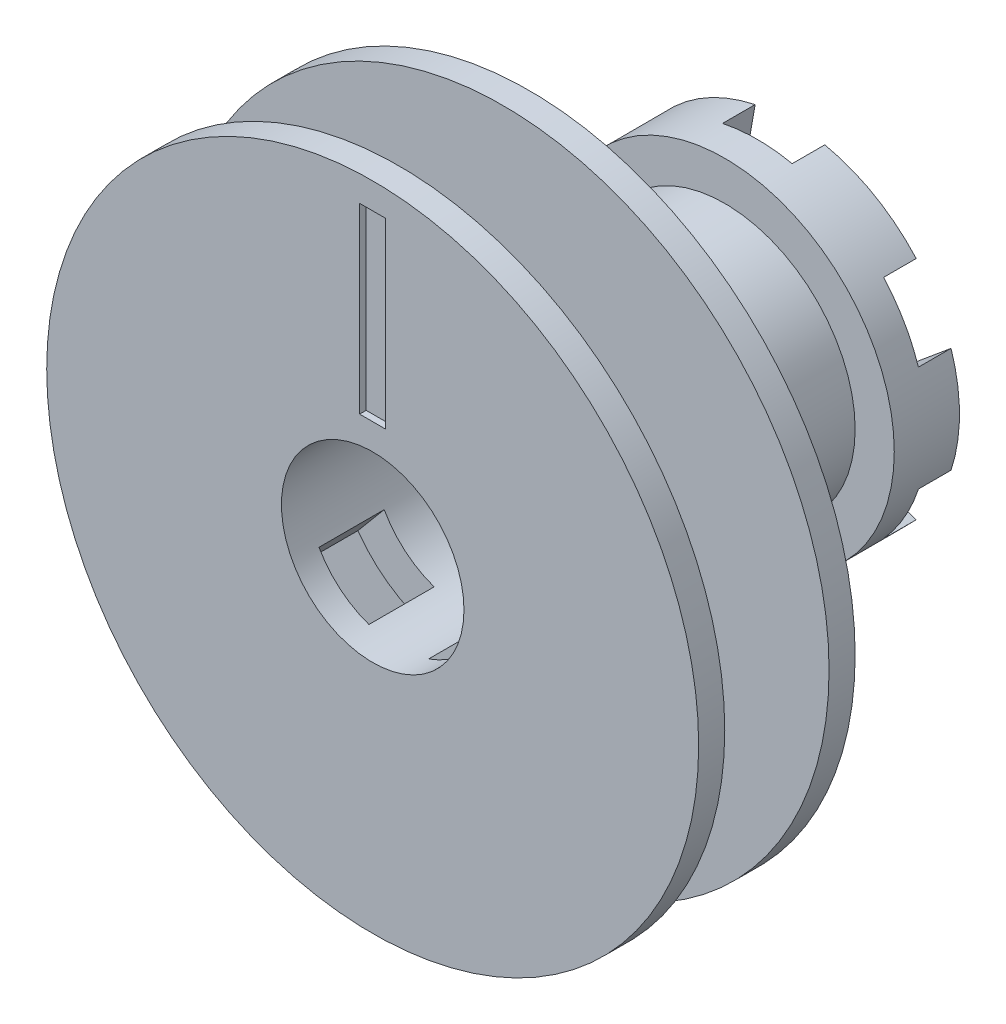
from build123d import *

# Parameters (mm, degrees)
SKETCH_3_R          = 13
EXTRUDE_1_DEPTH     = 5
CUT_EXTRUDE_2_DEPTH = 2.5
SKETCH_11_R         = 10
EXTRUDE_2_DEPTH     = 15
SKETCH_6_R          = 2
CUT_EXTRUDE_3_DEPTH = 33
SKETCH_7_R          = 7
CUT_EXTRUDE_4_DEPTH = 23
CUT_EXTRUDE_6_DEPTH = 5
FILLET_1_R          = 1
SKETCH_10_W         = 2
SKETCH_10_H         = 14
CUT_EXTRUDE_7_DEPTH = 0.5


with BuildPart() as part:
    # ｽｹｯﾁ3 → ﾎﾞｽ - 押し出し1 (new body)
    with BuildSketch(Plane.XY):
        Circle(SKETCH_3_R)
    extrude(amount=EXTRUDE_1_DEPTH)

    # ｽｹｯﾁ2 → ｶｯﾄ - 押し出し2 (cut)
    with BuildSketch(Plane.XY):
        with BuildLine():
            Line((3.75, 6.495190528), (2.463350586, 13.926501921))
            ThreePointArc((2.463350586, 13.926501921), (0, 16), (-2.463350586, 13.926501921))
            Line((-2.463350586, 13.926501921), (-3.75, 6.495190528))
            Line((-3.75, 6.495190528), (-10.829029157, 9.096575147))
            ThreePointArc((-10.829029157, 9.096575147), (-13.856406461, 8), (-13.292379743, 4.829926775))
            Line((-13.292379743, 4.829926775), (-7.5, 0))
            Line((-7.5, 0), (-13.292379743, -4.829926775))
            ThreePointArc((-13.292379743, -4.829926775), (-13.856406461, -8), (-10.829029157, -9.096575147))
            Line((-10.829029157, -9.096575147), (-3.75, -6.495190528))
            Line((-3.75, -6.495190528), (-2.463350586, -13.926501921))
            ThreePointArc((-2.463350586, -13.926501921), (0, -16), (2.463350586, -13.926501921))
            Line((2.463350586, -13.926501921), (3.75, -6.495190528))
            Line((3.75, -6.495190528), (10.829029157, -9.096575147))
            ThreePointArc((10.829029157, -9.096575147), (13.856406461, -8), (13.292379743, -4.829926775))
            Line((13.292379743, -4.829926775), (7.5, 0))
            Line((7.5, 0), (13.292379743, 4.829926775))
            ThreePointArc((13.292379743, 4.829926775), (13.856406461, 8), (10.829029157, 9.096575147))
            Line((10.829029157, 9.096575147), (3.75, 6.495190528))
        make_face()
    extrude(amount=CUT_EXTRUDE_2_DEPTH, mode=Mode.SUBTRACT)

    # ｽｹｯﾁ11 → ﾎﾞｽ - 押し出し2 (add)
    with BuildSketch(Plane.XY.offset(5)):
        Circle(SKETCH_11_R)
    extrude(amount=EXTRUDE_2_DEPTH)

    # ｽｹｯﾁ5 → 回転1 (revolve)
    with BuildSketch(Plane(origin=(0, 0, 0), x_dir=(1, 0, 0), z_dir=(0, 1, 0))):
        Polygon((0, -20), (25, -20), (25, -22), (10, -22), (10, -30), (25, -30), (25, -32), (0, -32), align=None)
    revolve(axis=Axis((0, 0, 0), (0, 0, 1)))

    # ｽｹｯﾁ6 → ｶｯﾄ - 押し出し3 (cut, through all)
    with BuildSketch(Plane.XY.offset(32)):
        Circle(SKETCH_6_R)
    extrude(amount=-CUT_EXTRUDE_3_DEPTH, mode=Mode.SUBTRACT)

    # ｽｹｯﾁ7 → ｶｯﾄ - 押し出し4 (cut)
    with BuildSketch(Plane.XY.offset(32)):
        Circle(SKETCH_7_R)
    extrude(amount=-CUT_EXTRUDE_4_DEPTH, mode=Mode.SUBTRACT)

    # ｽｹｯﾁ9 → ｶｯﾄ - 押し出し6 (cut)
    with BuildSketch(Plane(origin=(0, 0, 30), x_dir=(-1, 0, 0), z_dir=(0, 0, -1))):
        Polygon((-3.843473937, -0.691164305), (-11.556925253, -9.883697623), (-7.726703038, -13.097635671), (-0.013251721, -3.905102354), align=None)
    cut_extrude_6 = extrude(amount=CUT_EXTRUDE_6_DEPTH, mode=Mode.SUBTRACT)

    # ﾐﾗｰ1: ｶｯﾄ - 押し出し6 across plane
    add(cut_extrude_6.mirror(Plane(origin=(0, 0, 0), x_dir=(0, 0, 1), z_dir=(1, 0, 0))), mode=Mode.SUBTRACT)

    # ﾌｨﾚｯﾄ1
    fillet_1_edges = [part.edges().sort_by_distance(p)[0] for p in [
        (4.308653161, -9.024162451, 27.5),
        (-4.308653161, -9.024162451, 27.5),
    ]]
    fillet(fillet_1_edges, radius=FILLET_1_R)

    # ｽｹｯﾁ10 → ｶｯﾄ - 押し出し7 (cut)
    with BuildSketch(Plane.XY.offset(32)):
        with Locations((0, 16)):
            Rectangle(SKETCH_10_W, SKETCH_10_H)
    extrude(amount=-CUT_EXTRUDE_7_DEPTH, mode=Mode.SUBTRACT)


solid = part.part
